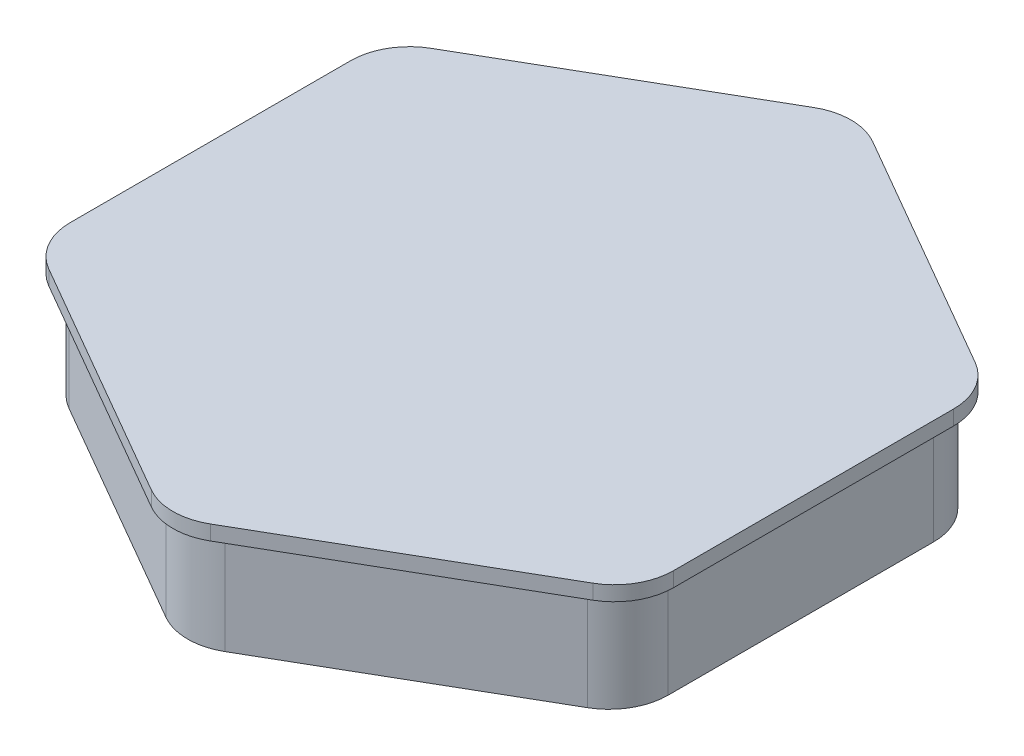
from build123d import *

# Parameters (mm, degrees)
BOSS_EXTRUDE2_DEPTH = 35
BOSS_EXTRUDE3_DEPTH = 5
SCALE1_SCALE        = 0.3


with BuildPart() as part:
    # Sketch2 → Boss-Extrude2 (new body)
    with BuildSketch(Plane(origin=(0, 0, 0), x_dir=(1, 0, 0), z_dir=(0, 1, 0))):
        with BuildLine():
            Line((-10, 107.320508076), (-87.942286341, 62.320508076))
            ThreePointArc((-87.942286341, 62.320508076), (-95.262794416, 55), (-97.942286341, 45))
            Line((-97.942286341, 45), (-97.942286341, -45))
            ThreePointArc((-97.942286341, -45), (-95.262794416, -55), (-87.942286341, -62.320508076))
            Line((-87.942286341, -62.320508076), (-10, -107.320508076))
            ThreePointArc((-10, -107.320508076), (0, -110), (10, -107.320508076))
            Line((10, -107.320508076), (87.942286341, -62.320508076))
            ThreePointArc((87.942286341, -62.320508076), (95.262794416, -55), (97.942286341, -45))
            Line((97.942286341, -45), (97.942286341, 45))
            ThreePointArc((97.942286341, 45), (95.262794416, 55), (87.942286341, 62.320508076))
            Line((87.942286341, 62.320508076), (10, 107.320508076))
            ThreePointArc((10, 107.320508076), (0, 110), (-10, 107.320508076))
        make_face()
    extrude(amount=BOSS_EXTRUDE2_DEPTH)

    # Sketch5 → Boss-Extrude3 (add)
    with BuildSketch(Plane(origin=(0, 35, 0), x_dir=(1, 0, 0), z_dir=(0, 1, 0))):
        with BuildLine():
            Line((-10, 112.320508076), (-92.27241336, 64.820508076))
            ThreePointArc((-92.27241336, 64.820508076), (-99.592921435, 57.5), (-102.27241336, 47.5))
            Line((-102.27241336, 47.5), (-102.27241336, -47.5))
            ThreePointArc((-102.27241336, -47.5), (-99.592921435, -57.5), (-92.27241336, -64.820508076))
            Line((-92.27241336, -64.820508076), (-10, -112.320508076))
            ThreePointArc((-10, -112.320508076), (0, -115), (10, -112.320508076))
            Line((10, -112.320508076), (92.27241336, -64.820508076))
            ThreePointArc((92.27241336, -64.820508076), (99.592921435, -57.5), (102.27241336, -47.5))
            Line((102.27241336, -47.5), (102.27241336, 47.5))
            ThreePointArc((102.27241336, 47.5), (99.592921435, 57.5), (92.27241336, 64.820508076))
            Line((92.27241336, 64.820508076), (10, 112.320508076))
            ThreePointArc((10, 112.320508076), (0, 115), (-10, 112.320508076))
        make_face()
    extrude(amount=BOSS_EXTRUDE3_DEPTH)


with BuildPart() as part_1:
    # Scale1: scaled about (0, 20.196243732, 0)
    add(part.part.scale(SCALE1_SCALE).moved(Location((0, 14.137370612, 0))))


solid = part_1.part
